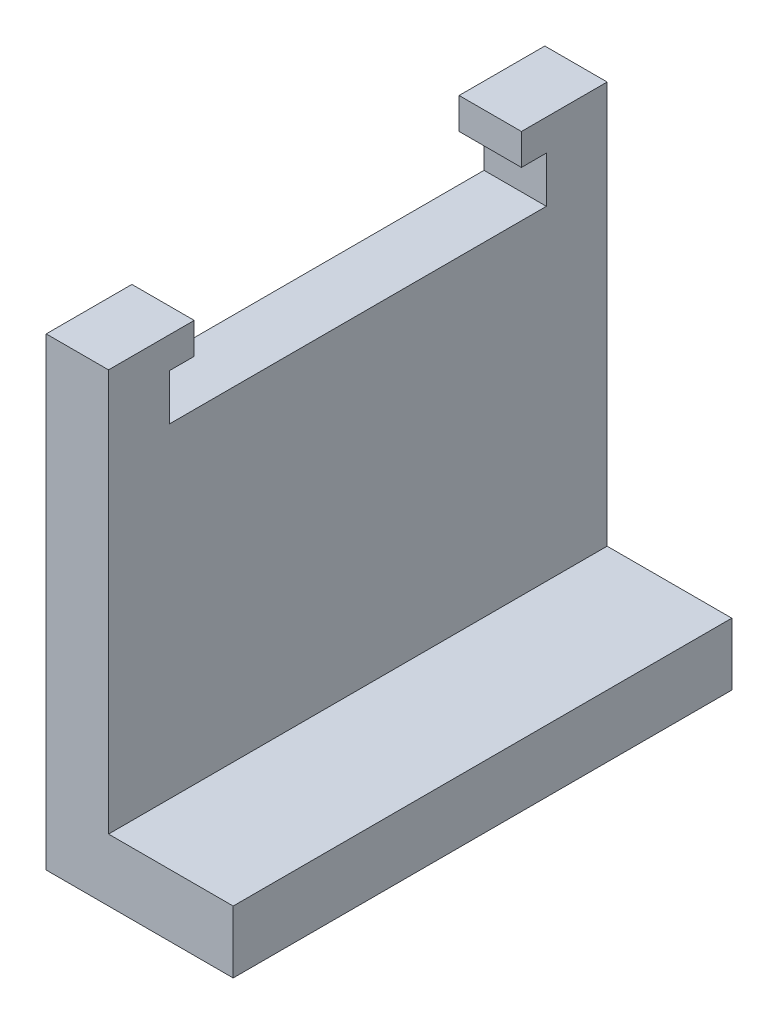
from build123d import *

# Parameters (mm, degrees)
BOSS_EXTRUDE1_DEPTH = 10
SKETCH2_W           = 80
SKETCH2_H           = 10
BOSS_EXTRUDE2_DEPTH = 20


with BuildPart() as part:
    # Sketch1 → Boss-Extrude1 (new body)
    with BuildSketch(Plane(origin=(0, 0, 0), x_dir=(0, 0, -1), z_dir=(1, 0, 0))):
        Polygon((0, 0), (80, 0), (80, 74.5), (66.25, 74.5), (66.25, 69.5), (70.25, 69.5), (70.25, 62.1), (9.75, 62.1), (9.75, 69.5), (13.75, 69.5), (13.75, 74.5), (0, 74.5), align=None)
    extrude(amount=BOSS_EXTRUDE1_DEPTH)

    # Sketch2 → Boss-Extrude2 (add)
    with BuildSketch(Plane(origin=(10, 0, 0), x_dir=(0, 0, -1), z_dir=(1, 0, 0))):
        with Locations((40, 5)):
            Rectangle(SKETCH2_W, SKETCH2_H)
    extrude(amount=BOSS_EXTRUDE2_DEPTH)


solid = part.part
